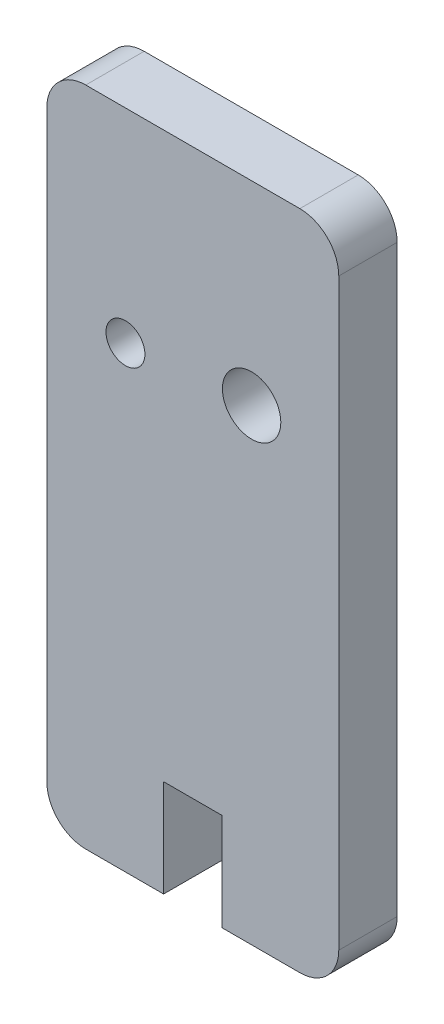
from build123d import *

# Parameters (mm, degrees)
SKETCH1_R           = 1.5
SKETCH1_R_2         = 1
BOSS_EXTRUDE1_DEPTH = 3
SKETCH4_W           = 3
SKETCH4_H           = 5
CUT_EXTRUDE1_DEPTH  = 4


with BuildPart() as part:
    # Sketch1 → Boss-Extrude1 (new body)
    with BuildSketch(Plane.XY):
        with BuildLine():
            Line((2, 0), (13, 0))
            ThreePointArc((13, 0), (14.414213562, 0.585786438), (15, 2))
            Line((15, 2), (15, 32))
            ThreePointArc((15, 32), (14.414213562, 33.414213562), (13, 34))
            Line((13, 34), (2, 34))
            ThreePointArc((2, 34), (0.585786438, 33.414213562), (0, 32))
            Line((0, 32), (0, 2))
            ThreePointArc((0, 2), (0.585786438, 0.585786438), (2, 0))
        make_face()
        with Locations((10.521654895, 24)):
            Circle(SKETCH1_R, mode=Mode.SUBTRACT)
        with Locations((4.038452424, 23.533003519)):
            Circle(SKETCH1_R_2, mode=Mode.SUBTRACT)
    extrude(amount=BOSS_EXTRUDE1_DEPTH)

    # Sketch4 → Cut-Extrude1 (cut, through all)
    with BuildSketch(Plane.XY.offset(3)):
        with Locations((7.5, 2.5)):
            Rectangle(SKETCH4_W, SKETCH4_H)
    extrude(amount=-CUT_EXTRUDE1_DEPTH, mode=Mode.SUBTRACT)


solid = part.part
